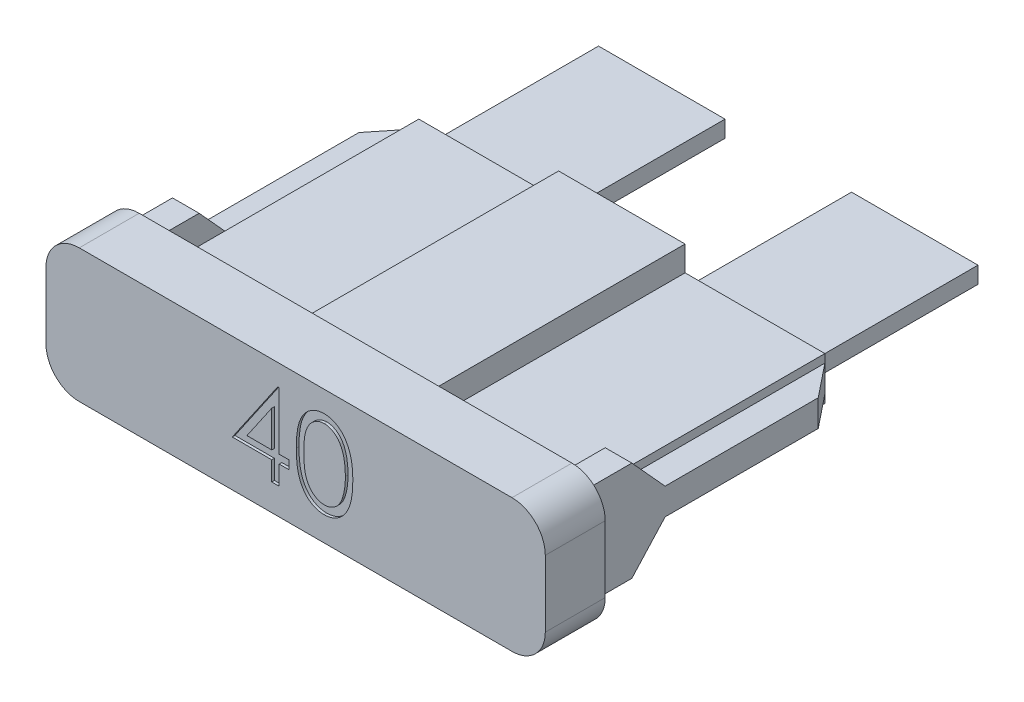
from build123d import *

# Parameters (mm, degrees)
EXTRUDE1_DEPTH       = 2.286
EXTRUDE2_DEPTH       = 10.16
EXTRUDE3_DEPTH       = 1.016
EXTRUDE4_DEPTH       = 1.016
CHAMFER1_SIZE        = 1.016
CHAMFER1_SIZE2       = 1.27
BLADE_DEPTH          = 0.635
CUT_EXTRUDE_40_DEPTH = 0.1016


with BuildPart() as part:
    # Sketch1 → Extrude1 (new body)
    with BuildSketch(Plane.XY):
        with BuildLine():
            Line((1.27, 0), (17.78, 0))
            ThreePointArc((17.78, 0), (18.678025612, 0.371974388), (19.05, 1.27))
            Line((19.05, 1.27), (19.05, 3.81))
            ThreePointArc((19.05, 3.81), (18.678025612, 4.708025612), (17.78, 5.08))
            Line((17.78, 5.08), (1.27, 5.08))
            ThreePointArc((1.27, 5.08), (0.371974388, 4.708025612), (0, 3.81))
            Line((0, 3.81), (0, 1.27))
            ThreePointArc((0, 1.27), (0.371974388, 0.371974388), (1.27, 0))
        make_face()
    extrude(amount=EXTRUDE1_DEPTH)

    # Sketch2 → Extrude2 (add)
    with BuildSketch(Plane(origin=(0, 0, 0), x_dir=(-1, 0, 0), z_dir=(0, 0, -1))):
        Polygon((-11.938, 4.318), (-11.938, 3.3655), (-17.272, 3.3655), (-17.272, 1.7145), (-11.938, 1.7145), (-11.938, 0.762), (-7.112, 0.762), (-7.112, 1.7145), (-1.778, 1.7145), (-1.778, 3.3655), (-7.112, 3.3655), (-7.112, 4.318), align=None)
        Polygon((-7.62, 2.2225), (-7.62, 1.27), (-11.43, 1.27), (-11.43, 2.2225), (-16.764, 2.2225), (-16.764, 2.8575), (-11.43, 2.8575), (-11.43, 3.81), (-7.62, 3.81), (-7.62, 2.8575), (-2.286, 2.8575), (-2.286, 2.2225), align=None, mode=Mode.SUBTRACT)
    extrude(amount=EXTRUDE2_DEPTH)

    # Sketch3 → Extrude3 (add)
    with BuildSketch(Plane.ZY.offset(-1.778)):
        Polygon((-10.16, 3.048), (-3.048, 3.048), (-1.778, 4.445), (0, 4.445), (0, 0.635), (-1.778, 0.635), (-3.048, 2.032), (-10.16, 2.032), align=None)
    extrude(amount=EXTRUDE3_DEPTH)

    # Sketch4 → Extrude4 (add)
    with BuildSketch(Plane(origin=(17.272, 0, 0), x_dir=(0, 0, -1), z_dir=(1, 0, 0))):
        Polygon((3.048, 3.048), (10.16, 3.048), (10.16, 2.032), (3.048, 2.032), (1.778, 0.635), (0, 0.635), (0, 4.445), (1.778, 4.445), align=None)
    extrude(amount=EXTRUDE4_DEPTH)

    # Chamfer1
    chamfer1_edges = [part.edges().sort_by_distance(p)[0] for p in [
        (0.762, 2.54, -10.16),
        (18.288, 2.54, -10.16),
    ]]
    chamfer1_side = [part.faces().sort_by_distance(p)[0] for p in [
        (11.759168847, 3.84175, -10.16),
    ]]
    chamfer(chamfer1_edges, length=CHAMFER1_SIZE, length2=CHAMFER1_SIZE2, reference=chamfer1_side[0])

    # Sketch8 → Blade (add)
    with BuildSketch(Plane(origin=(0, 2.2225, 0), x_dir=(-1, 0, 0), z_dir=(0, 1, 0))):
        with BuildLine():
            Line((-2.286, 0), (-7.112, 0))
            Line((-7.112, 0), (-7.112, -6.858))
            Line((-7.112, -6.858), (-7.366, -6.858))
            ThreePointArc((-7.366, -6.858), (-7.815012806, -6.672012806), (-8.001, -6.223))
            Line((-8.001, -6.223), (-8.001, -3.175))
            ThreePointArc((-8.001, -3.175), (-8.410171827, -2.187171827), (-9.398, -1.778))
            Line((-9.398, -1.778), (-9.652, -1.778))
            ThreePointArc((-9.652, -1.778), (-10.639828173, -2.187171827), (-11.049, -3.175))
            Line((-11.049, -3.175), (-11.049, -6.223))
            ThreePointArc((-11.049, -6.223), (-11.234987194, -6.672012806), (-11.684, -6.858))
            Line((-11.684, -6.858), (-11.938, -6.858))
            Line((-11.938, -6.858), (-11.938, 0))
            Line((-11.938, 0), (-16.764, 0))
            Line((-16.764, 0), (-16.764, -16.51))
            Line((-16.764, -16.51), (-11.938, -16.51))
            Line((-11.938, -16.51), (-11.938, -7.62))
            Line((-11.938, -7.62), (-10.922, -7.62))
            ThreePointArc((-10.922, -7.62), (-10.472987194, -7.434012806), (-10.287, -6.985))
            Line((-10.287, -6.985), (-10.287, -3.175))
            ThreePointArc((-10.287, -3.175), (-10.101012806, -2.725987194), (-9.652, -2.54))
            Line((-9.652, -2.54), (-9.398, -2.54))
            ThreePointArc((-9.398, -2.54), (-8.948987194, -2.725987194), (-8.763, -3.175))
            Line((-8.763, -3.175), (-8.763, -6.985))
            ThreePointArc((-8.763, -6.985), (-8.577012806, -7.434012806), (-8.128, -7.62))
            Line((-8.128, -7.62), (-7.112, -7.62))
            Line((-7.112, -7.62), (-7.112, -16.51))
            Line((-7.112, -16.51), (-2.286, -16.51))
            Line((-2.286, -16.51), (-2.286, 0))
        make_face()
    extrude(amount=BLADE_DEPTH)

    # Sketch6 → "40" (cut)
    with BuildSketch(Plane.XY.offset(2.286)):
        Polygon((8.840263421, 4.272410256), (8.898141026, 4.272410256), (8.898141026, 2.074333333), (9.264487179, 2.074333333), (9.264487179, 1.748692308), (8.898141026, 1.748692308), (8.898141026, 1.016), (8.613205128, 1.016), (8.613205128, 1.748692308), (7.107115385, 1.748692308), align=None)
        Polygon((8.613205128, 2.074333333), (8.613205128, 3.453219551), (7.666810897, 2.074333333), align=None, mode=Mode.SUBTRACT)
        with BuildLine():
            add(Edge.make_bspline(
                [(9.549423077, 2.602227965), (9.549720636, 2.653116309), (9.55029865, 2.751967652), (9.55672886, 2.896008006), (9.567410778, 3.031136268), (9.58204968, 3.157358907), (9.599864134, 3.274708507), (9.623645325, 3.382871466), (9.650689796, 3.482348394), (9.6820338, 3.573463681), (9.717401295, 3.657444883), (9.755895231, 3.735844887), (9.799043295, 3.808545069), (9.844379494, 3.876705779), (9.893739016, 3.939211273), (9.945717205, 3.99694426), (10.002342764, 4.048570441), (10.061690779, 4.095602444), (10.124298571, 4.136831607), (10.188381561, 4.17314702), (10.254380836, 4.204171185), (10.322476588, 4.228564652), (10.392056765, 4.248713063), (10.463364604, 4.262491609), (10.536517842, 4.27116109), (10.585894929, 4.271989917), (10.610936498, 4.272410256)],
                knots=[0, 0, 0, 0, 0.000152656, 0.000296537, 0.000432439, 0.000559218, 0.000677689, 0.000788344, 0.000891263, 0.000986803, 0.001077167, 0.001164489, 0.00124859, 0.001330617, 0.001409885, 0.001487322, 0.001563392, 0.001639481, 0.001714274, 0.001788036, 0.00186031, 0.001932743, 0.002004819, 0.002077414, 0.00215039, 0.002225483, 0.002225483, 0.002225483, 0.002225483], degree=3))
            add(Edge.make_bspline(
                [(10.610936498, 4.272410256), (10.636187254, 4.271967738), (10.686403062, 4.271087709), (10.760643974, 4.262629561), (10.833169756, 4.248595043), (10.903671211, 4.228709587), (10.972727449, 4.204039223), (11.039798333, 4.173117338), (11.105300471, 4.137122937), (11.168192946, 4.09482842), (11.229166204, 4.047673069), (11.286722571, 3.994366934), (11.340867284, 3.93544826), (11.392279883, 3.871547427), (11.439501746, 3.801438814), (11.484471931, 3.7263418), (11.524723706, 3.644943087), (11.563490162, 3.558600805), (11.596951928, 3.464925915), (11.627129165, 3.364446454), (11.651512229, 3.255975584), (11.671822498, 3.140082419), (11.687556796, 3.016341345), (11.699016407, 2.885017616), (11.705069849, 2.746024833), (11.706209856, 2.650994498), (11.706794872, 2.602227965)],
                knots=[0, 0, 0, 0, 7.5729e-05, 0.000150601, 0.00022382, 0.00029712, 0.000370151, 0.00044358, 0.000518452, 0.000594128, 0.000670717, 0.000749483, 0.000829148, 0.000910598, 0.000995274, 0.001082536, 0.001172987, 0.001267529, 0.001366317, 0.00147116, 0.001582092, 0.001699622, 0.00182403, 0.001956183, 0.00209498, 0.002241286, 0.002241286, 0.002241286, 0.002241286], degree=3))
            add(Edge.make_bspline(
                [(11.706794872, 2.602227965), (11.706203792, 2.553674134), (11.705052096, 2.459068975), (11.699084269, 2.32070159), (11.687328939, 2.190074794), (11.672624164, 2.066875303), (11.652257933, 1.951615891), (11.627216104, 1.843897713), (11.599411883, 1.743255591), (11.565090319, 1.650514012), (11.527524889, 1.564379235), (11.48665339, 1.483945464), (11.442865762, 1.408501756), (11.395160258, 1.338651986), (11.344311804, 1.273901347), (11.289232096, 1.215392789), (11.231473779, 1.161716537), (11.170321088, 1.113953989), (11.106447752, 1.072148487), (11.041170589, 1.034761637), (10.973331377, 1.004614835), (10.904467484, 0.978729477), (10.833593895, 0.958953353), (10.760798955, 0.945279212), (10.686452941, 0.935689035), (10.636195807, 0.934957443), (10.610936498, 0.934589744)],
                knots=[0, 0, 0, 0, 0.00014567, 0.000283833, 0.000415351, 0.000539048, 0.000655953, 0.000766265, 0.000870752, 0.000968942, 0.001062646, 0.001152529, 0.001239469, 0.001324145, 0.001406093, 0.001486191, 0.001564957, 0.001642439, 0.001718644, 0.001793826, 0.001867834, 0.001941084, 0.002014383, 0.002088227, 0.002163172, 0.002238901, 0.002238901, 0.002238901, 0.002238901], degree=3))
            add(Edge.make_bspline(
                [(10.610936498, 0.934589744), (10.585895624, 0.935012795), (10.536519906, 0.935846969), (10.463356634, 0.944477282), (10.392343275, 0.958352489), (10.323129405, 0.977780408), (10.255359924, 1.00156101), (10.189958292, 1.03254328), (10.126197322, 1.068224899), (10.064247125, 1.108860746), (10.005271807, 1.155416844), (9.948939501, 1.206910163), (9.896665377, 1.264625686), (9.84801159, 1.327652088), (9.80177081, 1.395409529), (9.75923545, 1.468823125), (9.719891889, 1.547601779), (9.68392958, 1.632254455), (9.652044721, 1.724016425), (9.623880014, 1.823937466), (9.601642171, 1.932899507), (9.582607633, 2.050027404), (9.5672548, 2.17582447), (9.556773376, 2.310358997), (9.550295184, 2.453547151), (9.549719084, 2.551763303), (9.549423077, 2.602227965)],
                knots=[0, 0, 0, 0, 7.5093e-05, 0.000148069, 0.000220664, 0.000291955, 0.000363574, 0.000435848, 0.000508744, 0.000582656, 0.000657851, 0.000733921, 0.000811359, 0.000891128, 0.000972628, 0.001057278, 0.001145453, 0.00123665, 0.001333, 0.001436702, 0.001547845, 0.001666417, 0.001792639, 0.001927908, 0.002071153, 0.002222537, 0.002222537, 0.002222537, 0.002222537], degree=3))
        make_face()
        with BuildLine():
            add(Edge.make_bspline(
                [(9.834358974, 2.6035), (9.83446733, 2.561092252), (9.834677627, 2.47878714), (9.840171466, 2.359186467), (9.847655605, 2.247634812), (9.857308782, 2.143990532), (9.871644313, 2.04860445), (9.8877069, 1.960820523), (9.907254095, 1.881103315), (9.930381719, 1.808905801), (9.956724328, 1.743002717), (9.985486076, 1.681678758), (10.016384017, 1.624209501), (10.050963532, 1.571111156), (10.088623625, 1.522210565), (10.128513653, 1.47664221), (10.172122355, 1.436004948), (10.23245075, 1.387267015), (10.312094694, 1.33690323), (10.41244325, 1.29304642), (10.515556774, 1.265485191), (10.585543979, 1.261980213), (10.620476763, 1.260230769)],
                knots=[0, 0, 0, 0, 0.00012721, 0.000246889, 0.000359088, 0.000462625, 0.000559048, 0.000648362, 0.000730273, 0.000805096, 0.000875606, 0.000943038, 0.001008214, 0.001071192, 0.001132889, 0.001193261, 0.001252653, 0.001311456, 0.001425798, 0.001534033, 0.001639084, 0.00174377, 0.00174377, 0.00174377, 0.00174377], degree=3))
            add(Edge.make_bspline(
                [(10.620476763, 1.260230769), (10.655635508, 1.261680185), (10.725880408, 1.264576023), (10.828508922, 1.292514878), (10.928140667, 1.334669388), (11.006220213, 1.384514626), (11.065622235, 1.431983896), (11.108182647, 1.472455755), (11.147246077, 1.517772864), (11.184295673, 1.566667225), (11.218276406, 1.620072978), (11.249176538, 1.677733315), (11.277373575, 1.739808354), (11.29343821, 1.783142332), (11.301651643, 1.805297877)],
                knots=[0, 0, 0, 0, 0.000105268, 0.000210319, 0.000316882, 0.000428931, 0.00048684, 0.000544871, 0.000604822, 0.000666135, 0.000728769, 0.000794503, 0.000862248, 0.000933117, 0.000933117, 0.000933117, 0.000933117], degree=3))
            add(Edge.make_bspline(
                [(11.301651643, 1.805297877), (11.311223603, 1.833627712), (11.330658789, 1.891149426), (11.355706613, 1.980379311), (11.375432796, 2.073998961), (11.393179564, 2.171448888), (11.405292693, 2.27344776), (11.415042495, 2.37967998), (11.420785332, 2.490225644), (11.421497214, 2.565332529), (11.421858974, 2.6035)],
                knots=[0, 0, 0, 0, 8.9703e-05, 0.000182136, 0.00027782, 0.000376635, 0.000479189, 0.000585832, 0.000696647, 0.000811146, 0.000811146, 0.000811146, 0.000811146], degree=3))
            add(Edge.make_bspline(
                [(11.421858974, 2.6035), (11.421359874, 2.641661298), (11.420383527, 2.716312955), (11.416651553, 2.825640161), (11.407014453, 2.929478773), (11.396310967, 3.02827613), (11.380529202, 3.121485333), (11.363513191, 3.209886682), (11.340652092, 3.292384997), (11.31623201, 3.370271903), (11.28828258, 3.442662497), (11.257516164, 3.509894289), (11.224657854, 3.572291861), (11.188968822, 3.629684015), (11.150872738, 3.682327822), (11.109364104, 3.729167775), (11.066089423, 3.771655596), (11.00547669, 3.820153784), (10.926125013, 3.869603679), (10.827386461, 3.91511119), (10.724633805, 3.941244427), (10.655170743, 3.944928957), (10.620476763, 3.946769231)],
                knots=[0, 0, 0, 0, 0.000114499, 0.000223985, 0.000328037, 0.000427282, 0.000522015, 0.000611574, 0.0006972, 0.000778663, 0.000856382, 0.000929811, 0.001000372, 0.00106779, 0.001132413, 0.001195057, 0.001255328, 0.001314131, 0.001427596, 0.001534925, 0.001639202, 0.001743255, 0.001743255, 0.001743255, 0.001743255], degree=3))
            add(Edge.make_bspline(
                [(10.620476763, 3.946769231), (10.585360726, 3.944926418), (10.515064678, 3.941237437), (10.411244034, 3.915208557), (10.311726515, 3.869839652), (10.232584674, 3.81999), (10.171929667, 3.772511674), (10.129218938, 3.731339677), (10.089172053, 3.686303432), (10.05228064, 3.636953123), (10.017728219, 3.583916683), (9.985995443, 3.526776875), (9.957404722, 3.465244137), (9.931020893, 3.399370657), (9.907822721, 3.327179371), (9.888687483, 3.247560356), (9.871009942, 3.160055639), (9.858495662, 3.064152943), (9.847370684, 2.960482704), (9.840221175, 2.848652565), (9.834659249, 2.728851306), (9.834461071, 2.646120641), (9.834358974, 2.6035)],
                knots=[0, 0, 0, 0, 0.00010532, 0.000210832, 0.000318741, 0.000432206, 0.000490612, 0.000549543, 0.000609914, 0.000671226, 0.000734205, 0.000799687, 0.00086712, 0.000937629, 0.001012452, 0.001094363, 0.001183173, 0.001280136, 0.001384369, 0.001495934, 0.001616249, 0.001744095, 0.001744095, 0.001744095, 0.001744095], degree=3))
        make_face(mode=Mode.SUBTRACT)
    extrude(amount=-CUT_EXTRUDE_40_DEPTH, mode=Mode.SUBTRACT)


solid = part.part
